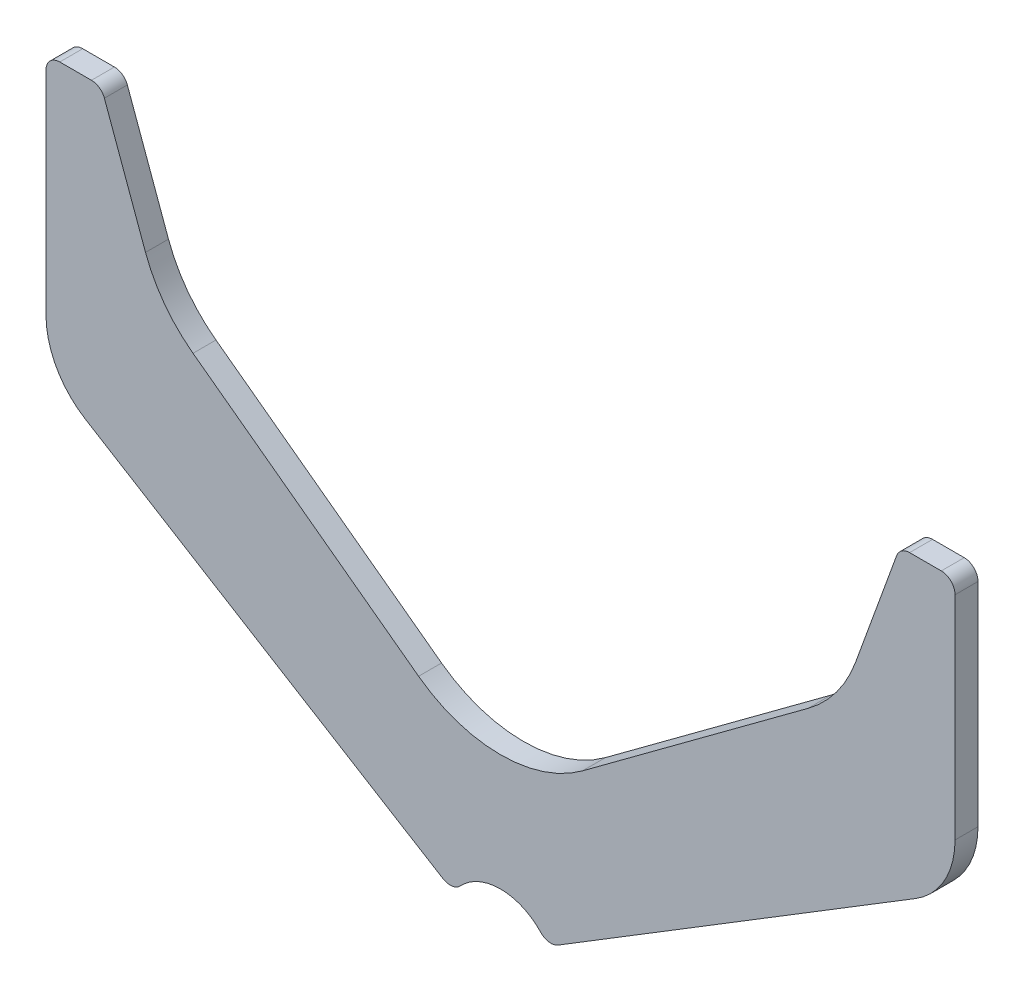
from build123d import *

# Parameters (mm, degrees)
BASE_EXTRUDE_DEPTH = 5


with BuildPart() as part:
    # Sketch1 → Base-Extrude (new body)
    with BuildSketch(Plane.XY):
        with BuildLine():
            Line((-99, 117), (-99, 70.747762378))
            ThreePointArc((-99, 70.747762378), (-96.704928127, 61.952580031), (-90.404974165, 55.40023942))
            Line((-90.404974165, 55.40023942), (-12.531200021, 7.679129249))
            ThreePointArc((-12.531200021, 7.679129249), (-10.560110304, 7.264321725), (-8.770963462, 8.189639794))
            ThreePointArc((-8.770963462, 8.189639794), (0, 12), (8.770963462, 8.189639794))
            ThreePointArc((8.770963462, 8.189639794), (10.560110304, 7.264321725), (12.531200021, 7.679129249))
            Line((12.531200021, 7.679129249), (90.404974165, 55.40023942))
            ThreePointArc((90.404974165, 55.40023942), (96.704928127, 61.952580031), (99, 70.747762378))
            Line((99, 70.747762378), (99, 117))
            ThreePointArc((99, 117), (98.121320344, 119.121320344), (96, 120))
            Line((96, 120), (89.100622615, 120))
            ThreePointArc((89.100622615, 120), (87.379893306, 119.457456133), (86.281544752, 118.02606043))
            Line((86.281544752, 118.02606043), (77.324366423, 93.416415229))
            ThreePointArc((77.324366423, 93.416415229), (73.17120218, 85.727281512), (66.978271402, 79.56131371))
            Line((66.978271402, 79.56131371), (17.844683603, 43.204371262))
            ThreePointArc((17.844683603, 43.204371262), (0, 37.320077081), (-17.844683603, 43.204371262))
            Line((-17.844683603, 43.204371262), (-66.978271402, 79.56131371))
            ThreePointArc((-66.978271402, 79.56131371), (-73.17120218, 85.727281512), (-77.324366423, 93.416415229))
            Line((-77.324366423, 93.416415229), (-86.281544752, 118.02606043))
            ThreePointArc((-86.281544752, 118.02606043), (-87.379893306, 119.457456133), (-89.100622615, 120))
            Line((-89.100622615, 120), (-96, 120))
            ThreePointArc((-96, 120), (-98.121320344, 119.121320344), (-99, 117))
        make_face()
    extrude(amount=BASE_EXTRUDE_DEPTH)


solid = part.part
